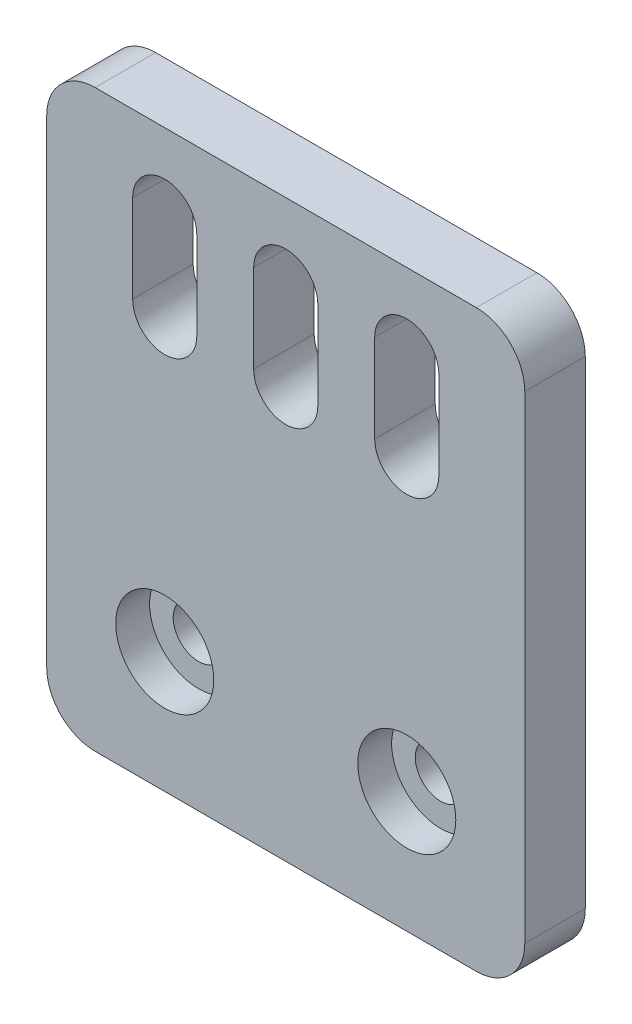
from build123d import *

# Parameters (mm, degrees)
CROQUIS2_W              = 39.5
CROQUIS2_H              = 47.5
CROQUIS2_R              = 2.1
SALIENTE_EXTRUIR1_DEPTH = 5
REDONDEO1_R             = 4
CROQUIS3_R              = 4.05
CORTAR_EXTRUIR1_DEPTH   = 2.8


with BuildPart() as part:
    # Croquis2 → Saliente-Extruir1 (new body)
    with BuildSketch(Plane.XY):
        with Locations((19.75, 23.75)):
            Rectangle(CROQUIS2_W, CROQUIS2_H)
        with Locations((9.75, 10)):
            Circle(CROQUIS2_R, mode=Mode.SUBTRACT)
        with Locations((29.75, 10)):
            Circle(CROQUIS2_R, mode=Mode.SUBTRACT)
        with BuildLine():
            Line((12.4, 41.171297972), (12.4, 33.911297972))
            ThreePointArc((12.4, 33.911297972), (9.75, 31.261297972), (7.1, 33.911297972))
            Line((7.1, 33.911297972), (7.1, 41.171297972))
            ThreePointArc((7.1, 41.171297972), (9.75, 43.821297972), (12.4, 41.171297972))
        make_face(mode=Mode.SUBTRACT)
        with BuildLine():
            Line((22.4, 41.171297972), (22.4, 33.911297972))
            ThreePointArc((22.4, 33.911297972), (19.75, 31.261297972), (17.1, 33.911297972))
            Line((17.1, 33.911297972), (17.1, 41.171297972))
            ThreePointArc((17.1, 41.171297972), (19.75, 43.821297972), (22.4, 41.171297972))
        make_face(mode=Mode.SUBTRACT)
        with BuildLine():
            Line((32.4, 41.171297972), (32.4, 33.911297972))
            ThreePointArc((32.4, 33.911297972), (29.75, 31.261297972), (27.1, 33.911297972))
            Line((27.1, 33.911297972), (27.1, 41.171297972))
            ThreePointArc((27.1, 41.171297972), (29.75, 43.821297972), (32.4, 41.171297972))
        make_face(mode=Mode.SUBTRACT)
    extrude(amount=SALIENTE_EXTRUIR1_DEPTH)

    # Redondeo1
    redondeo1_edges = [part.edges().sort_by_distance(p)[0] for p in [
        (0, 47.5, 2.5),
        (39.5, 47.5, 2.5),
        (39.5, 0, 2.5),
        (0, 0, 2.5),
    ]]
    fillet(redondeo1_edges, radius=REDONDEO1_R)

    # Croquis3 → Cortar-Extruir1 (cut)
    with BuildSketch(Plane.XY.offset(5)):
        with Locations((29.75, 10)):
            Circle(CROQUIS3_R)
        with Locations((9.75, 10)):
            Circle(CROQUIS3_R)
    extrude(amount=-CORTAR_EXTRUIR1_DEPTH, mode=Mode.SUBTRACT)


solid = part.part
